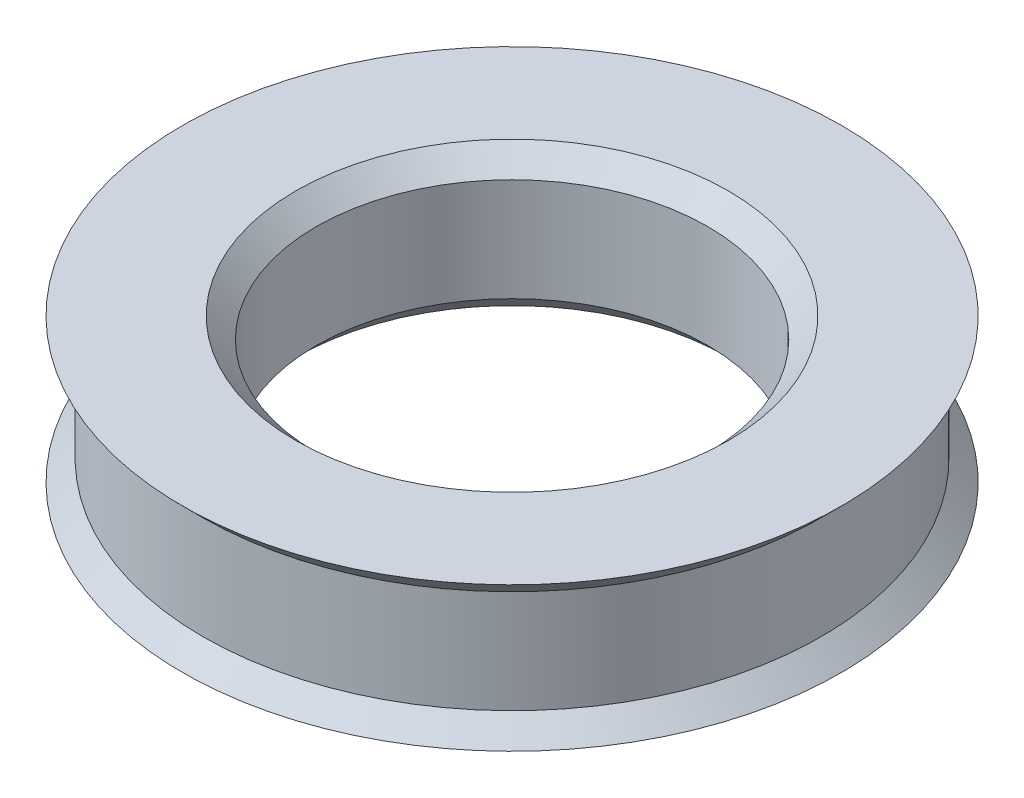
from build123d import *

# Parameters (mm, degrees)
CHAMFER1_SIZE = 1


with BuildPart() as part:
    # Sketch2 → Revolve1 (revolve)
    with BuildSketch(Plane.XY):
        Polygon((9.5, 3.5), (9.5, -3.5), (16, -3.5), (15, -2.5), (15, 2.5), (16, 3.5), align=None)
    revolve(axis=Axis((0, 0, 0), (0, 1, 0)))

    # Chamfer1
    chamfer1_edges = [part.edges().sort_by_distance(p)[0] for p in [
        (-9.5, -3.5, 0),
        (-9.5, 3.5, 0),
    ]]
    chamfer(chamfer1_edges, length=CHAMFER1_SIZE)


solid = part.part
